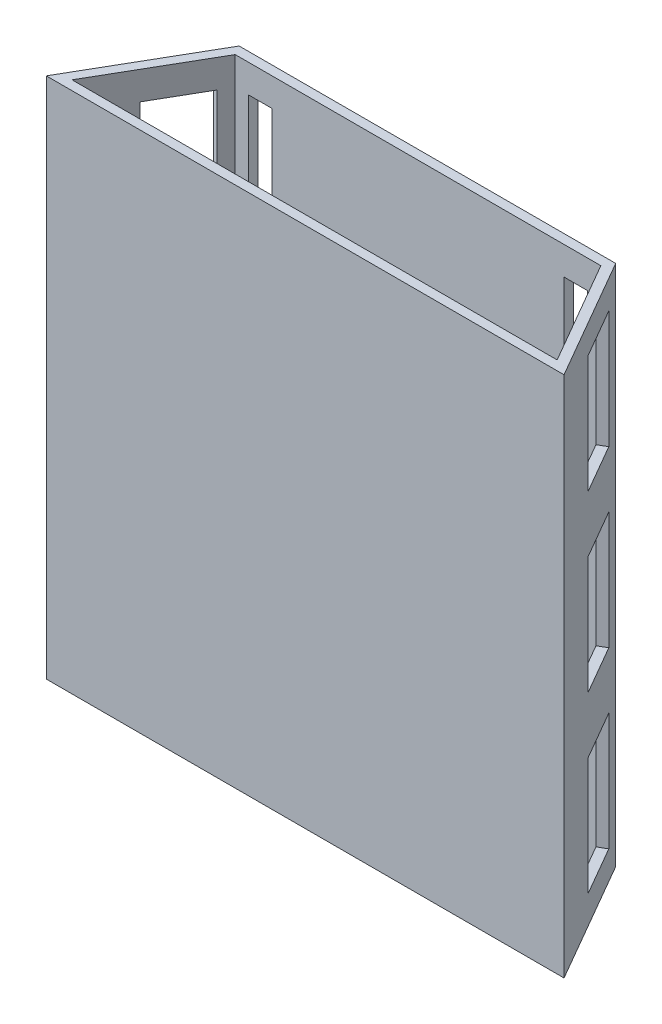
from build123d import *

# Parameters (mm, degrees)
EXTRUDE_1_DEPTH     = 111
SKETCH_3_W          = 12
SKETCH_3_H          = 25
CUT_EXTRUDE_1_DEPTH = 2
SKETCH_5_W          = 12
SKETCH_5_H          = 25
CUT_EXTRUDE_2_DEPTH = 2
SKETCH_6_W          = 5
SKETCH_6_H          = 99
CUT_EXTRUDE_3_DEPTH = 2


with BuildPart() as part:
    # 草圖1 → 填料-伸長1 (new body)
    with BuildSketch(Plane(origin=(0, 0, 0), x_dir=(1, 0, 0), z_dir=(0, 1, 0))):
        Polygon((-15, 5.665584657), (65, 5.665584657), (80, -20.315177457), (65, -20.315177457), (-15, -20.315177457), (-30, -20.315177457), align=None)
        Polygon((-13.845299462, 3.665584657), (63.845299462, 3.665584657), (76.535898385, -18.315177457), (65, -18.315177457), (-15, -18.315177457), (-26.535898385, -18.315177457), align=None, mode=Mode.SUBTRACT)
    extrude(amount=EXTRUDE_1_DEPTH)

    # 草圖3 → 除料-伸長1 (cut)
    with BuildSketch(Plane(origin=(51.20327012, 0, -29.562221787), x_dir=(-0.5, 0, -0.866025404), z_dir=(0.866025404, 0, -0.5))):
        with Locations((-37.59345976, 92.5)):
            Rectangle(SKETCH_3_W, SKETCH_3_H)
        with Locations((-37.59345976, 55.5)):
            Rectangle(SKETCH_3_W, SKETCH_3_H)
        with Locations((-37.59345976, 18.5)):
            Rectangle(SKETCH_3_W, SKETCH_3_H)
    extrude(amount=-CUT_EXTRUDE_1_DEPTH, mode=Mode.SUBTRACT)

    # 草圖5 → 除料-伸長2 (cut)
    with BuildSketch(Plane(origin=(-13.70327012, 0, -7.911586693), x_dir=(-0.5, 0, 0.866025404), z_dir=(-0.866025404, 0, -0.5))):
        with Locations((12.59345976, 92.5)):
            Rectangle(SKETCH_5_W, SKETCH_5_H)
        with Locations((12.59345976, 55.5)):
            Rectangle(SKETCH_5_W, SKETCH_5_H)
        with Locations((12.59345976, 18.5)):
            Rectangle(SKETCH_5_W, SKETCH_5_H)
    extrude(amount=-CUT_EXTRUDE_2_DEPTH, mode=Mode.SUBTRACT)

    # 草圖6 → 除料-伸長3 (cut)
    with BuildSketch(Plane(origin=(0, 0, -5.665584657), x_dir=(-1, 0, 0), z_dir=(0, 0, -1))):
        with Locations((-58.5, 55.5)):
            Rectangle(SKETCH_6_W, SKETCH_6_H)
        with Locations((8.5, 55.5)):
            Rectangle(SKETCH_6_W, SKETCH_6_H)
    extrude(amount=-CUT_EXTRUDE_3_DEPTH, mode=Mode.SUBTRACT)


solid = part.part
